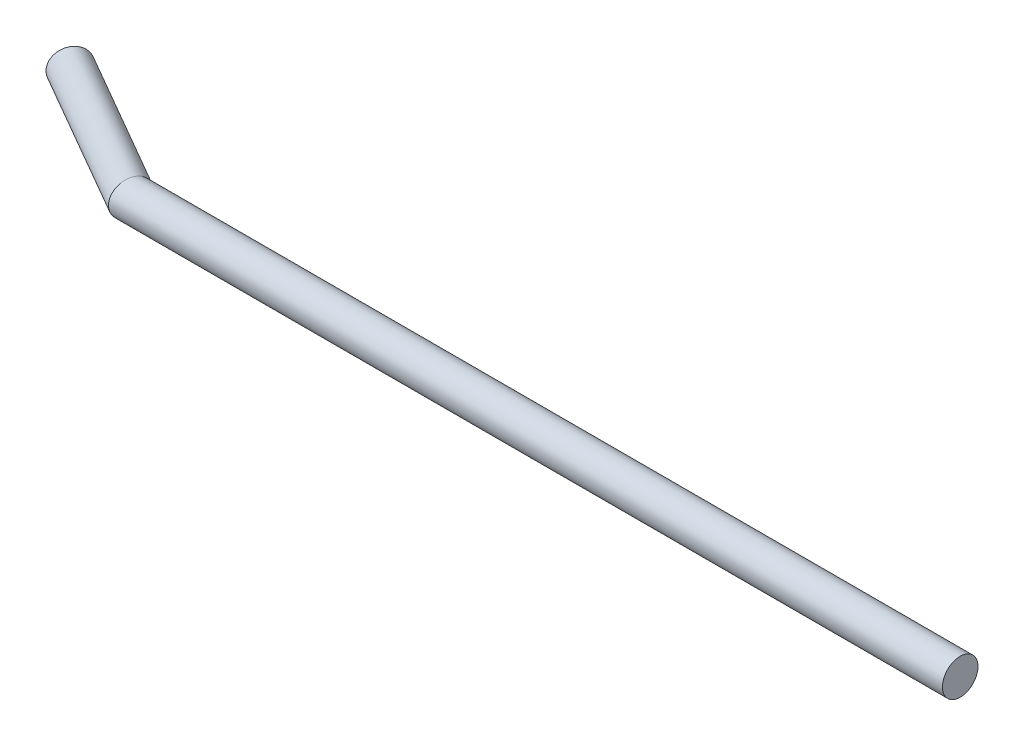
from build123d import *

# Parameters (mm, degrees)
SKETCH2_R = 1.5


with BuildPart() as part:
    # Sweep1: sweep along a path in Sketch1
    with BuildLine(Plane(origin=(0, 0, 0), x_dir=(1, 0, 0), z_dir=(0, 1, 0))) as sweep1_path:
        Line((0, 0), (-70, 0))
        Line((-70, 0), (-82.124355653, 7))
    # Sketch2 → Sweep1 (sweep)
    with BuildSketch(Plane(origin=(0, 0, 0), x_dir=(0, 0, -1), z_dir=(1, 0, 0))):
        Circle(SKETCH2_R)
    sweep(path=sweep1_path.line, transition=Transition.RIGHT)


solid = part.part
